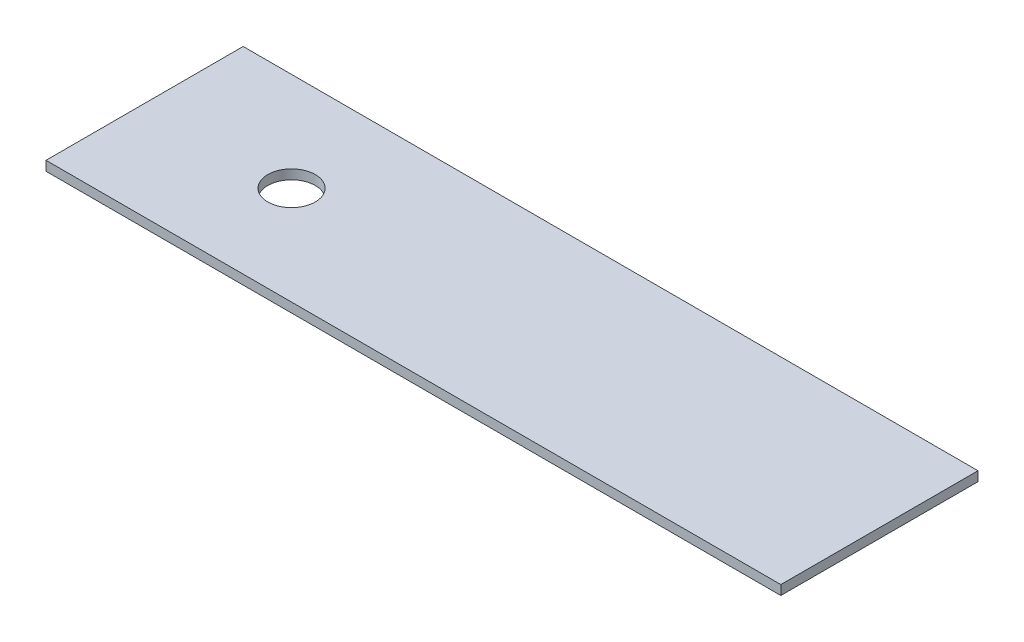
from build123d import *

# Parameters (mm, degrees)
SKETCH1_W           = 464
SKETCH1_H           = 124.5
SKETCH1_R           = 15
BOSS_EXTRUDE1_DEPTH = 6


with BuildPart() as part:
    # Sketch1 → Boss-Extrude1 (new body)
    with BuildSketch(Plane(origin=(0, 0, 0), x_dir=(1, 0, 0), z_dir=(0, 1, 0))):
        Rectangle(SKETCH1_W, SKETCH1_H)
        with Locations((-139.2, 0)):
            Circle(SKETCH1_R, mode=Mode.SUBTRACT)
    extrude(amount=BOSS_EXTRUDE1_DEPTH)


solid = part.part
